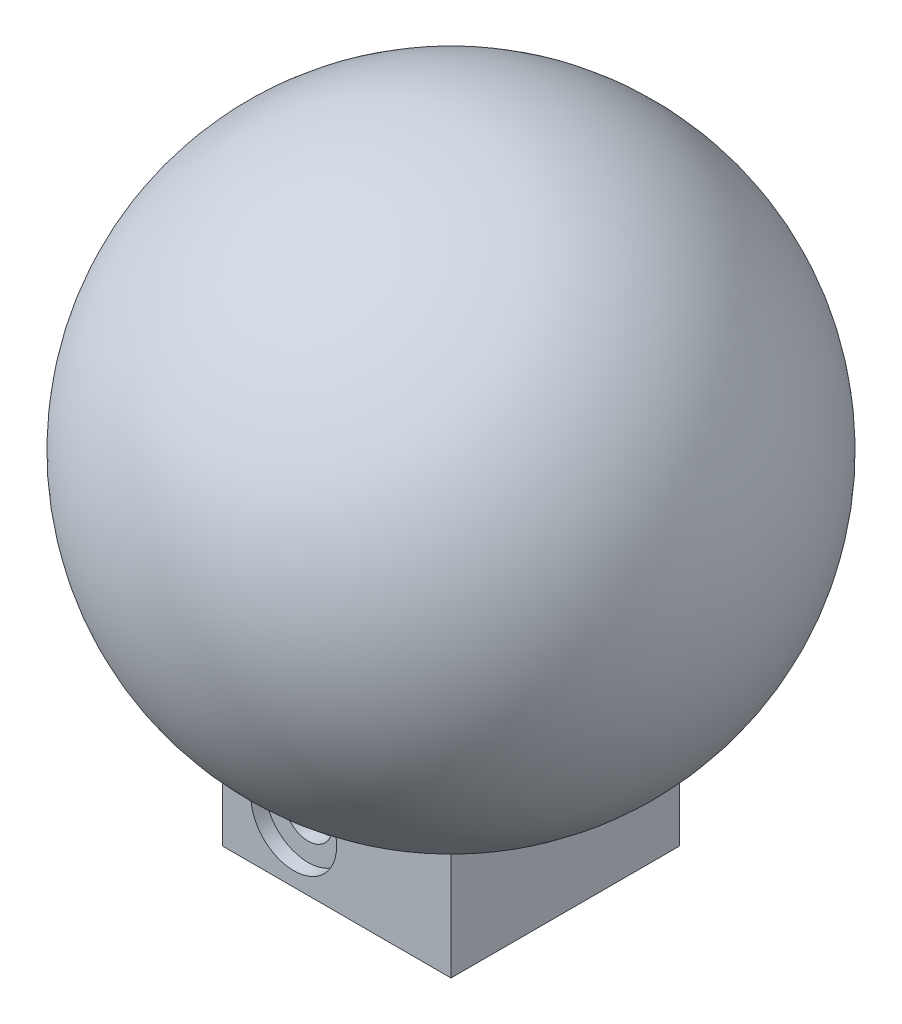
from build123d import *

# Parameters (mm, degrees)
BOSS_EXTRUDE1_REACH             = 50.99
BOSS_EXTRUDE1_END_RADIUS        = 20
SKETCH2_W                       = 16
SKETCH2_H                       = 16
SKETCH2_W_2                     = 12
SKETCH2_H_2                     = 12
BOSS_EXTRUDE1_DIRECTION_2_DEPTH = 4
SKETCH3_W                       = 12
SKETCH3_H                       = 12
CUT_EXTRUDE1_DEPTH              = 10
SKETCH4_R                       = 1.7
CUT_EXTRUDE2_DEPTH              = 3
SKETCH5_R                       = 1.7
CUT_EXTRUDE3_DEPTH              = 3
CUT_EXTRUDE4_DEPTH              = 53.763623833
CUT_EXTRUDE4_DEPTH_BACK         = 1
SKETCH6_R                       = 3
CUT_EXTRUDE5_DEPTH              = 53.763623833
CUT_EXTRUDE5_DEPTH_BACK         = 1
SKETCH7_R                       = 3


with BuildPart() as part:
    # Sketch1 → Revolve1 (revolve)
    with BuildSketch(Plane.XY):
        with BuildLine():
            Line((0, 0), (0, 40))
            ThreePointArc((0, 40), (20, 20), (0, 0))
        make_face()
    revolve(axis=Axis((0, 0, 0), (0, 1, 0)))

    # Boss-Extrude1: up to this sphere (the profile starts outside it)
    boss_extrude1_end = Location((0, 20, 0)) * Sphere(BOSS_EXTRUDE1_END_RADIUS, mode=Mode.PRIVATE)
    # Sketch2 → Boss-Extrude1 (add, up to the surface)
    with BuildSketch(Plane(origin=(0, 0, 0), x_dir=(1, 0, 0), z_dir=(0, 1, 0)), mode=Mode.PRIVATE) as boss_extrude1_sk1:
        Rectangle(SKETCH2_W, SKETCH2_H)
        Rectangle(SKETCH2_W_2, SKETCH2_H_2, mode=Mode.SUBTRACT)
    boss_extrude1_tool1 = extrude(boss_extrude1_sk1.sketch, amount=BOSS_EXTRUDE1_REACH, mode=Mode.PRIVATE) - boss_extrude1_end
    add(boss_extrude1_tool1.solids().sort_by_distance((0, 0, -7.773726))[0])

    # Sketch2 → Boss-Extrude1 direction 2 (add)
    with BuildSketch(Plane(origin=(0, 0, 0), x_dir=(1, 0, 0), z_dir=(0, 1, 0))):
        Rectangle(SKETCH2_W, SKETCH2_H)
        Rectangle(SKETCH2_W_2, SKETCH2_H_2, mode=Mode.SUBTRACT)
    extrude(amount=-BOSS_EXTRUDE1_DIRECTION_2_DEPTH)

    # Sketch3 → Cut-Extrude1 (cut)
    with BuildSketch(Plane.XZ.offset(4)):
        Rectangle(SKETCH3_W, SKETCH3_H)
    extrude(amount=-CUT_EXTRUDE1_DEPTH, mode=Mode.SUBTRACT)

    # Sketch4 → Cut-Extrude2 (cut)
    with BuildSketch(Plane(origin=(0, 0, 6), x_dir=(-1, 0, 0), z_dir=(0, 0, -1))):
        with Locations((3, 0)):
            Circle(SKETCH4_R)
    extrude(amount=-CUT_EXTRUDE2_DEPTH, mode=Mode.SUBTRACT)

    # Sketch5 → Cut-Extrude3 (cut)
    with BuildSketch(Plane.XY.offset(-6)):
        with Locations((3, 0)):
            Circle(SKETCH5_R)
    extrude(amount=-CUT_EXTRUDE3_DEPTH, mode=Mode.SUBTRACT)

    # Sketch6 → Cut-Extrude4 (cut, two sides: drawn at the far end of the back side and taken through both)
    with BuildSketch(Plane(origin=(0, 0, -8), x_dir=(-1, 0, 0), z_dir=(0, 0, -1)).offset(-CUT_EXTRUDE4_DEPTH_BACK)):
        with Locations((-3, 0)):
            Circle(SKETCH6_R)
    extrude(amount=CUT_EXTRUDE4_DEPTH + CUT_EXTRUDE4_DEPTH_BACK, mode=Mode.SUBTRACT)

    # Sketch7 → Cut-Extrude5 (cut, two sides: drawn at the far end of the back side and taken through both)
    with BuildSketch(Plane.XY.offset(8).offset(-CUT_EXTRUDE5_DEPTH_BACK)):
        with Locations((-3, 0)):
            Circle(SKETCH7_R)
    extrude(amount=CUT_EXTRUDE5_DEPTH + CUT_EXTRUDE5_DEPTH_BACK, mode=Mode.SUBTRACT)


solid = part.part
